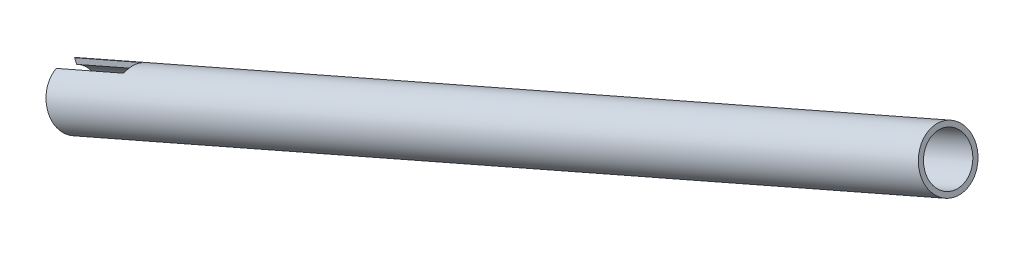
from build123d import *

# Parameters (mm, degrees)
CUT_EXTRUDE1_START = -3.175
CUT_EXTRUDE1_DEPTH = 6.35


with BuildPart() as part:
    # Sketch1 → Revolve1 (revolve)
    with BuildSketch(Plane.XY):
        Polygon((-283.220746633, 125.445945871), (-583.174614745, -5.911189845), (-582.512324093, -7.423529785), (-282.558455982, 123.933605931), align=None)
    revolve(axis=Axis((-487.684573981, 44.502168488, 0), (-0.9160145, -0.401145155, 0)))

    # Sketch2 → Cut-Extrude1 (cut)
    with BuildSketch(Plane.XY.offset(CUT_EXTRUDE1_START)):
        Polygon((-566.887371, 20.215633386), (-590.154139302, 10.026546442), (-582.512324093, -7.423529785), (-559.245555791, 2.76555716), align=None)
    extrude(amount=CUT_EXTRUDE1_DEPTH, mode=Mode.SUBTRACT)


solid = part.part
